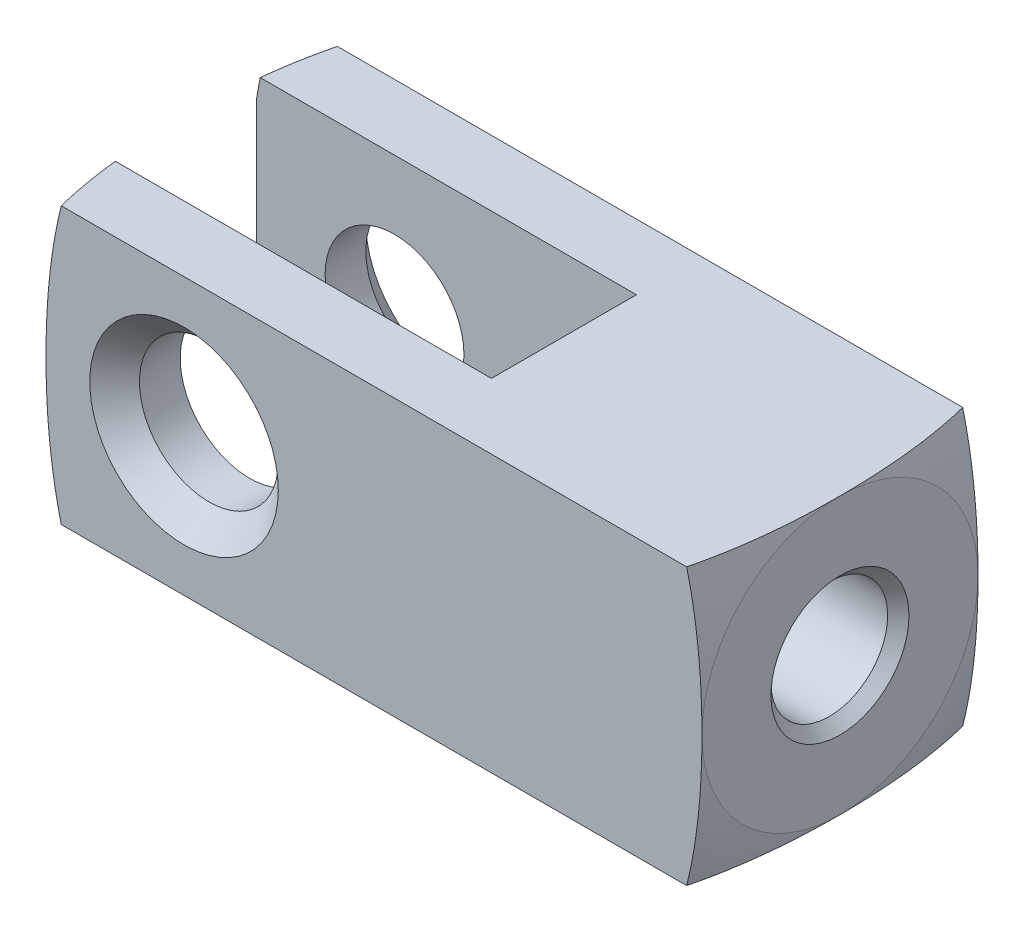
from build123d import *

# Parameters (mm, degrees)
BOSS_EXTRUDE1_DEPTH      = 6.35
BOSS_EXTRUDE1_DEPTH_BACK = 6.35
SKETCH1_W                = 30.1752
SKETCH1_H                = 12.7
CUT_EXTRUDE1_DEPTH       = 6.35
CUT_EXTRUDE1_DEPTH_BACK  = 6.35
SKETCH2_W                = 17.4752
SKETCH2_H                = 6.6675
HOLE1_D                  = 5.36702
HOLE1_DEPTH              = 11.176
HOLE1_CSINK_D            = 6.35
HOLE1_CSINK_ANGLE        = 90
SKETCH5_W                = 2.7051
SKETCH5_H                = 1.524


with BuildPart() as part:
    # Sketch1 → Boss-Extrude1 (new, two sides: drawn at the far end of the back side and taken through both)
    with BuildSketch(Plane.XY.offset(-BOSS_EXTRUDE1_DEPTH_BACK)):
        with Locations((8.7376, 0)):
            Rectangle(SKETCH1_W, SKETCH1_H)
    extrude(amount=BOSS_EXTRUDE1_DEPTH + BOSS_EXTRUDE1_DEPTH_BACK)

    # Sketch2 → Cut-Extrude1 (cut, two sides: drawn at the far end of the back side and taken through both)
    with BuildSketch(Plane(origin=(0, 0, 0), x_dir=(1, 0, 0), z_dir=(0, 1, 0)).offset(-CUT_EXTRUDE1_DEPTH_BACK)):
        with Locations((2.3876, 0)):
            Rectangle(SKETCH2_W, SKETCH2_H)
    extrude(amount=CUT_EXTRUDE1_DEPTH + CUT_EXTRUDE1_DEPTH_BACK, mode=Mode.SUBTRACT)

    # Hole1
    with Locations(Plane(origin=(23.8252, 0, 0), x_dir=(0, 0, -1), z_dir=(1, 0, 0))):
        with Locations((0, 0)):
            CounterSinkHole(HOLE1_D / 2, HOLE1_CSINK_D / 2, depth=HOLE1_DEPTH, counter_sink_angle=HOLE1_CSINK_ANGLE)

    # Sketch5 → Hole2 (revolve, cut)
    with BuildSketch(Plane(origin=(12.6492, 0, 0), x_dir=(0, 0, -1), z_dir=(0, 1, 0))):
        with Locations((1.35255, 0.762)):
            Rectangle(SKETCH5_W, SKETCH5_H)
    revolve(axis=Axis((-97.3508, 0, 0), (1, 0, 0)), mode=Mode.SUBTRACT)

    # Sketch7 → Cut-Revolve1 (revolve, cut)
    with BuildSketch(Plane(origin=(0, 0, 0), x_dir=(0, 0, -1), z_dir=(1, 0, 0))):
        Polygon((-6.35, 0), (-6.35, 4.33705), (-5.207, 3.19405), (5.207, 3.19405), (6.35, 4.33705), (6.35, 0), align=None)
    revolve(axis=Axis((0, 0, -6.35), (0, 0, 1)), mode=Mode.SUBTRACT)

    # Sketch8 → Cut-Revolve2 (revolve, cut)
    with BuildSketch(Plane.XY):
        with BuildLine():
            Line((23.8252, 0), (23.8252, 6.35))
            ThreePointArc((23.8252, 6.35), (22.869586956, 9.650754782), (21.2852, 12.7))
            Line((21.2852, 12.7), (30.1752, 12.7))
            Line((30.1752, 12.7), (30.1752, 0))
            Line((30.1752, 0), (23.8252, 0))
        make_face()
    revolve(axis=Axis((30.1752, 0, 0), (-1, 0, 0)), mode=Mode.SUBTRACT)

    # Sketch9 → Cut-Revolve3 (revolve, cut)
    with BuildSketch(Plane.XY):
        with BuildLine():
            Line((-12.7, 0), (-12.7, 12.7))
            Line((-12.7, 12.7), (-3.81, 12.7))
            ThreePointArc((-3.81, 12.7), (-5.394386956, 9.650754782), (-6.35, 6.35))
            Line((-6.35, 6.35), (-6.35, 0))
            Line((-6.35, 0), (-12.7, 0))
        make_face()
    revolve(axis=Axis((-6.35, 0, 0), (-1, 0, 0)), mode=Mode.SUBTRACT)


solid = part.part
